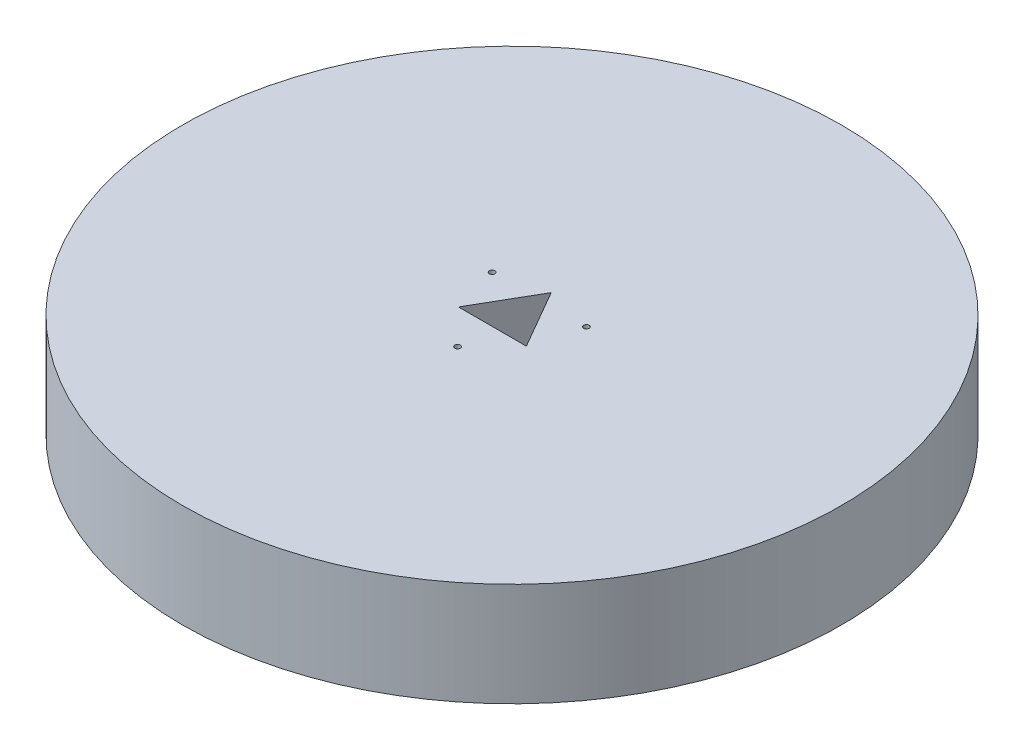
from build123d import *

# Parameters (mm, degrees)
SKETCH1_R           = 60.5
BOSS_EXTRUDE1_DEPTH = 19
SKETCH2_R           = 0.5
CUT_EXTRUDE2_DEPTH  = 20


with BuildPart() as part:
    # Sketch1 → Boss-Extrude1 (new body)
    with BuildSketch(Plane(origin=(0, 0, 0), x_dir=(1, 0, 0), z_dir=(0, 1, 0))):
        Circle(SKETCH1_R)
    extrude(amount=BOSS_EXTRUDE1_DEPTH)

    # Sketch2 → Cut-Extrude2 (cut, through all)
    with BuildSketch(Plane(origin=(0, 19, 0), x_dir=(1, 0, 0), z_dir=(0, 1, 0))):
        with Locations((-8.660254038, 5)):
            Circle(SKETCH2_R)
        with Locations((8.660254038, 5)):
            Circle(SKETCH2_R)
        with Locations((0, -10)):
            Circle(SKETCH2_R)
        Polygon((0, 7.2), (6.235382907, -3.6), (-6.235382907, -3.6), align=None)
    extrude(amount=-CUT_EXTRUDE2_DEPTH, mode=Mode.SUBTRACT)


solid = part.part
